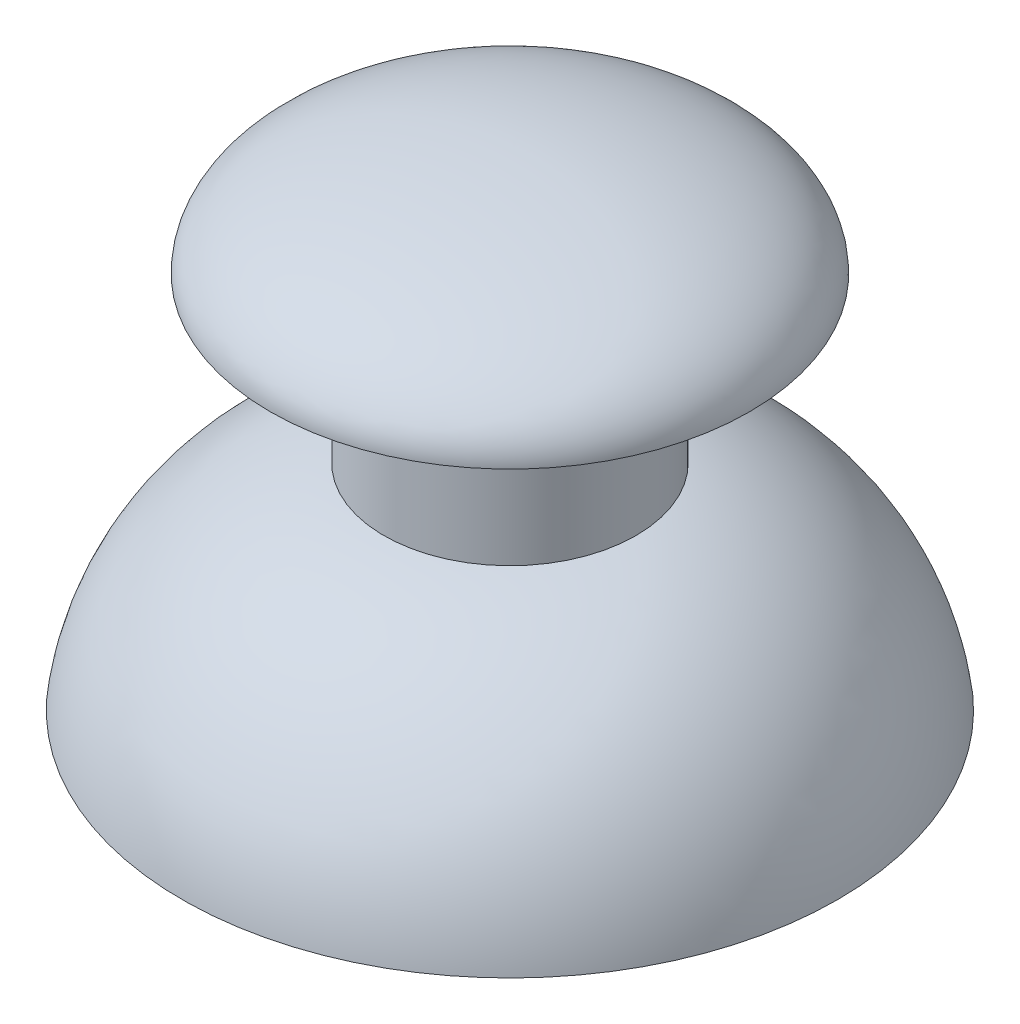
from build123d import *


with BuildPart() as part:
    # Esquisse1 → Révolution1 (revolve)
    with BuildSketch(Plane.XY):
        with BuildLine():
            Line((9.5, 15), (5, 14))
            Line((5, 14), (5, 8.5))
            ThreePointArc((5, 8.5), (10.368876984, 5.538354809), (13, 0))
            Line((13, 0), (11.985457402, 0.032026579))
            ThreePointArc((11.985457402, 0.032026579), (9.294219515, 5.201524496), (4, 7.638266133))
            Line((4, 7.638266133), (4, 14))
            Line((4, 14), (3, 14))
            Line((3, 14), (3, 3))
            Line((3, 3), (1, 3))
            Line((1, 3), (1, 8.5))
            Line((1, 8.5), (0, 8.5))
            Line((0, 8.5), (0, 19))
            add(Edge.make_bspline(
                [(9.5, 15), (9.5, 19), (0, 19)],
                knots=[3.141592654, 3.141592654, 3.141592654, 4.71238898, 4.71238898, 4.71238898], degree=2, weights=[1, 0.707106781, 1]))
        make_face()
    revolve(axis=Axis((0, 0, 0), (0, 1, 0)))


solid = part.part
